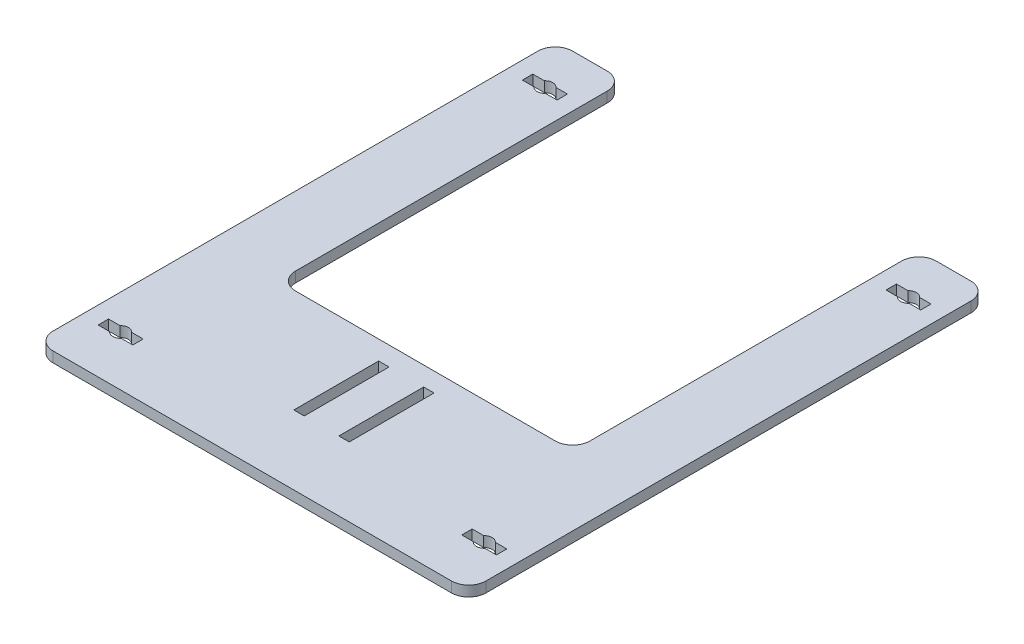
from build123d import *

# Parameters (mm, degrees)
BOSS_EXTRUDE1_DEPTH  = 6
FILLET1_R            = 10
SKETCH2_OUTSIDE_W    = 330.112
SKETCH2_OUTSIDE_H    = 380.112
SKETCH2_OUTSIDE_W_2  = 6
SKETCH2_OUTSIDE_H_2  = 49
CUT_EXTRUDE1_DEPTH   = 7
CUT_EXTRUDE2_DEPTH   = 7
LPATTERN1_COUNT      = 2
LPATTERN1_PITCH      = 245
LPATTERN1_COUNT_DIR2 = 2
LPATTERN1_PITCH_DIR2 = 210


with BuildPart() as part:
    # Sketch1 → Boss-Extrude1 (new body)
    with BuildSketch(Plane(origin=(0, 0, 0), x_dir=(1, 0, 0), z_dir=(0, 1, 0))):
        Polygon((-164.115526796, 87.380429132), (-124.115526796, 87.380429132), (-124.115526796, -112.619570868), (45.884473204, -112.619570868), (45.884473204, 87.380429132), (85.884473204, 87.380429132), (85.884473204, -212.619570868), (-164.115526796, -212.619570868), align=None)
    extrude(amount=BOSS_EXTRUDE1_DEPTH)

    # Fillet1
    fillet1_edges = [part.edges().sort_by_distance(p)[0] for p in [
        (-164.115526796, 3, -87.380429132),
        (-124.115526796, 3, -87.380429132),
        (-124.115526796, 3, 112.619570868),
        (45.884473204, 3, 112.619570868),
        (45.884473204, 3, -87.380429132),
        (85.884473204, 3, -87.380429132),
        (85.884473204, 3, 212.619570868),
        (-164.115526796, 3, 212.619570868),
    ]]
    fillet(fillet1_edges, radius=FILLET1_R)

    # Sketch2 outside → Cut-Extrude1 (cut, through all)
    with BuildSketch(Plane.XZ):
        with Locations((-39.116, 62.62)):
            Rectangle(SKETCH2_OUTSIDE_W, SKETCH2_OUTSIDE_H)
        with BuildLine():
            Line((-164.115526796, 202.619570868), (-164.115526796, -77.380429132))
            ThreePointArc((-164.115526796, -77.380429132), (-161.186594608, -84.451496944), (-154.115526796, -87.380429132))
            Line((-154.115526796, -87.380429132), (-134.115526796, -87.380429132))
            ThreePointArc((-134.115526796, -87.380429132), (-127.044458984, -84.451496944), (-124.115526796, -77.380429132))
            Line((-124.115526796, -77.380429132), (-124.115526796, 102.619570868))
            ThreePointArc((-124.115526796, 102.619570868), (-121.186594608, 109.69063868), (-114.115526796, 112.619570868))
            Line((-114.115526796, 112.619570868), (35.884473204, 112.619570868))
            ThreePointArc((35.884473204, 112.619570868), (42.955541016, 109.69063868), (45.884473204, 102.619570868))
            Line((45.884473204, 102.619570868), (45.884473204, -77.380429132))
            ThreePointArc((45.884473204, -77.380429132), (48.813405392, -84.451496944), (55.884473204, -87.380429132))
            Line((55.884473204, -87.380429132), (75.884473204, -87.380429132))
            ThreePointArc((75.884473204, -87.380429132), (82.955541016, -84.451496944), (85.884473204, -77.380429132))
            Line((85.884473204, -77.380429132), (85.884473204, 202.619570868))
            ThreePointArc((85.884473204, 202.619570868), (82.955541016, 209.69063868), (75.884473204, 212.619570868))
            Line((75.884473204, 212.619570868), (-154.115526796, 212.619570868))
            ThreePointArc((-154.115526796, 212.619570868), (-161.186594608, 209.69063868), (-164.115526796, 202.619570868))
        make_face(mode=Mode.SUBTRACT)
        with Locations((-52.115526796, 148.119570868)):
            Rectangle(SKETCH2_OUTSIDE_W_2, SKETCH2_OUTSIDE_H_2)
        with Locations((-26.115526796, 148.119570868)):
            Rectangle(SKETCH2_OUTSIDE_W_2, SKETCH2_OUTSIDE_H_2)
    extrude(amount=-CUT_EXTRUDE1_DEPTH, mode=Mode.SUBTRACT)

    # Sketch5 → Cut-Extrude2 (cut, through all)
    with BuildSketch(Plane(origin=(0, 0, 0), x_dir=(-1, 0, 0), z_dir=(0, -1, 0))):
        with BuildLine():
            Line((134.115526796, 58.380429132), (140.76142483, 58.380429132))
            ThreePointArc((140.76142483, 58.380429132), (144.115526796, 56.880429132), (147.469628762, 58.380429132))
            Line((147.469628762, 58.380429132), (154.115526796, 58.380429132))
            Line((154.115526796, 58.380429132), (154.115526796, 64.380429132))
            Line((154.115526796, 64.380429132), (147.469628762, 64.380429132))
            ThreePointArc((147.469628762, 64.380429132), (144.115526796, 65.880429132), (140.76142483, 64.380429132))
            Line((140.76142483, 64.380429132), (134.115526796, 64.380429132))
            Line((134.115526796, 64.380429132), (134.115526796, 58.380429132))
        make_face()
    cut_extrude2 = extrude(amount=-CUT_EXTRUDE2_DEPTH, mode=Mode.SUBTRACT)

    # LPattern1: Cut-Extrude2 2 × 2
    with Locations(*[(j * LPATTERN1_PITCH_DIR2, 0, i * LPATTERN1_PITCH) for i in range(LPATTERN1_COUNT) for j in range(LPATTERN1_COUNT_DIR2) if (i, j) != (0, 0)]):
        add(cut_extrude2, mode=Mode.SUBTRACT)


solid = part.part
